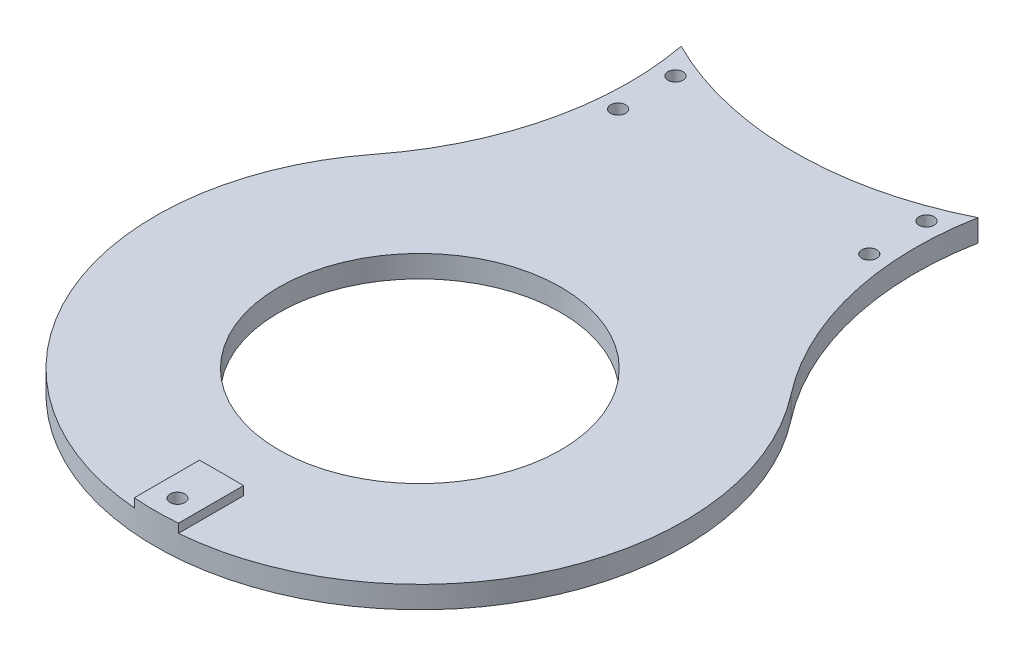
from build123d import *

# Parameters (mm, degrees)
CROQUIS1_R              = 32
SALIENTE_EXTRUIR1_DEPTH = 5
SALIENTE_EXTRUIR2_DEPTH = 2
CROQUIS3_R              = 1.7
CORTAR_EXTRUIR1_DEPTH   = 19
CROQUIS4_R              = 2.95
CORTAR_EXTRUIR2_DEPTH   = 3
CROQUIS5_R              = 1.7
CORTAR_EXTRUIR3_DEPTH   = 5
CROQUIS9_R              = 75
CORTAR_EXTRUIR6_DEPTH   = 37


with BuildPart() as part:
    # Croquis1 → Saliente-Extruir1 (new body)
    with BuildSketch(Plane(origin=(0, 0, 0), x_dir=(1, 0, 0), z_dir=(0, 1, 0))):
        with BuildLine():
            ThreePointArc((-47.29361892, 36.923076923), (0, -60), (47.29361892, 36.923076923))
            ThreePointArc((47.29361892, 36.923076923), (32.46950766, 80), (47.29361892, 123.076923077))
            ThreePointArc((47.29361892, 123.076923077), (0, 220), (-47.29361892, 123.076923077))
            ThreePointArc((-47.29361892, 123.076923077), (-32.46950766, 80), (-47.29361892, 36.923076923))
        make_face()
        Circle(CROQUIS1_R, mode=Mode.SUBTRACT)
        with Locations((0, 160)):
            Circle(CROQUIS1_R, mode=Mode.SUBTRACT)
    extrude(amount=SALIENTE_EXTRUIR1_DEPTH)

    # Croquis2 → Saliente-Extruir2 (add)
    with BuildSketch(Plane(origin=(0, 5, 0), x_dir=(1, 0, 0), z_dir=(0, 1, 0))):
        with BuildLine():
            Line((5, 205), (-5, 205))
            Line((-5, 205), (-5, 219.791303716))
            ThreePointArc((-5, 219.791303716), (0, 220), (5, 219.791303716))
            Line((5, 219.791303716), (5, 205))
        make_face()
        with BuildLine():
            Line((-5, -45), (5, -45))
            Line((5, -45), (5, -59.791303716))
            ThreePointArc((5, -59.791303716), (0, -60), (-5, -59.791303716))
            Line((-5, -59.791303716), (-5, -45))
        make_face()
    extrude(amount=SALIENTE_EXTRUIR2_DEPTH)

    # Croquis3 → Cortar-Extruir1 (cut)
    with BuildSketch(Plane(origin=(0, 7, 0), x_dir=(1, 0, 0), z_dir=(0, 1, 0))):
        with Locations((0, 215)):
            Circle(CROQUIS3_R)
        with Locations((0, -55)):
            Circle(CROQUIS3_R)
    extrude(amount=-CORTAR_EXTRUIR1_DEPTH, mode=Mode.SUBTRACT)

    # Croquis4 → Cortar-Extruir2 (cut)
    with BuildSketch(Plane.XZ):
        with Locations((0, 55)):
            Circle(CROQUIS4_R)
        with Locations((0, -215)):
            Circle(CROQUIS4_R)
    extrude(amount=-CORTAR_EXTRUIR2_DEPTH, mode=Mode.SUBTRACT)

    # Croquis5 → Cortar-Extruir3 (cut)
    with BuildSketch(Plane.XZ):
        with Locations((-28.5, -73.5)):
            Circle(CROQUIS5_R)
        with Locations((-28.5, -86.5)):
            Circle(CROQUIS5_R)
        with Locations((28.5, -86.5)):
            Circle(CROQUIS5_R)
        with Locations((28.5, -73.5)):
            Circle(CROQUIS5_R)
    extrude(amount=-CORTAR_EXTRUIR3_DEPTH, mode=Mode.SUBTRACT)

    # Croquis9 → Cortar-Extruir6 (cut)
    with BuildSketch(Plane.XZ):
        with Locations((0, -160)):
            Circle(CROQUIS9_R)
    extrude(amount=-CORTAR_EXTRUIR6_DEPTH, mode=Mode.SUBTRACT)


solid = part.part
